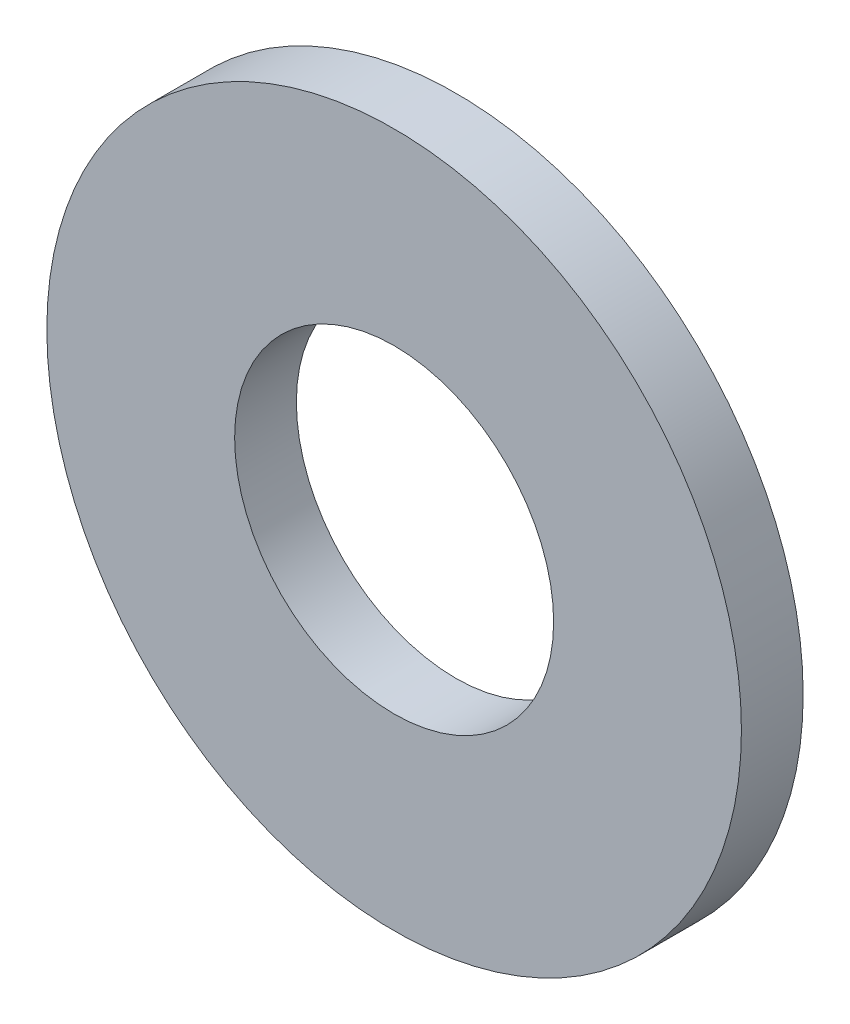
from build123d import *

# Parameters (mm, degrees)
SKETCH_1_R      = 3.375
SKETCH_1_R_2    = 1.55
EXTRUDE_1_DEPTH = 0.6


with BuildPart() as part:
    # Эскиз1 → Бобышка-Вытянуть1 (new body)
    with BuildSketch(Plane.XY):
        Circle(SKETCH_1_R)
        Circle(SKETCH_1_R_2, mode=Mode.SUBTRACT)
    extrude(amount=EXTRUDE_1_DEPTH)


solid = part.part
